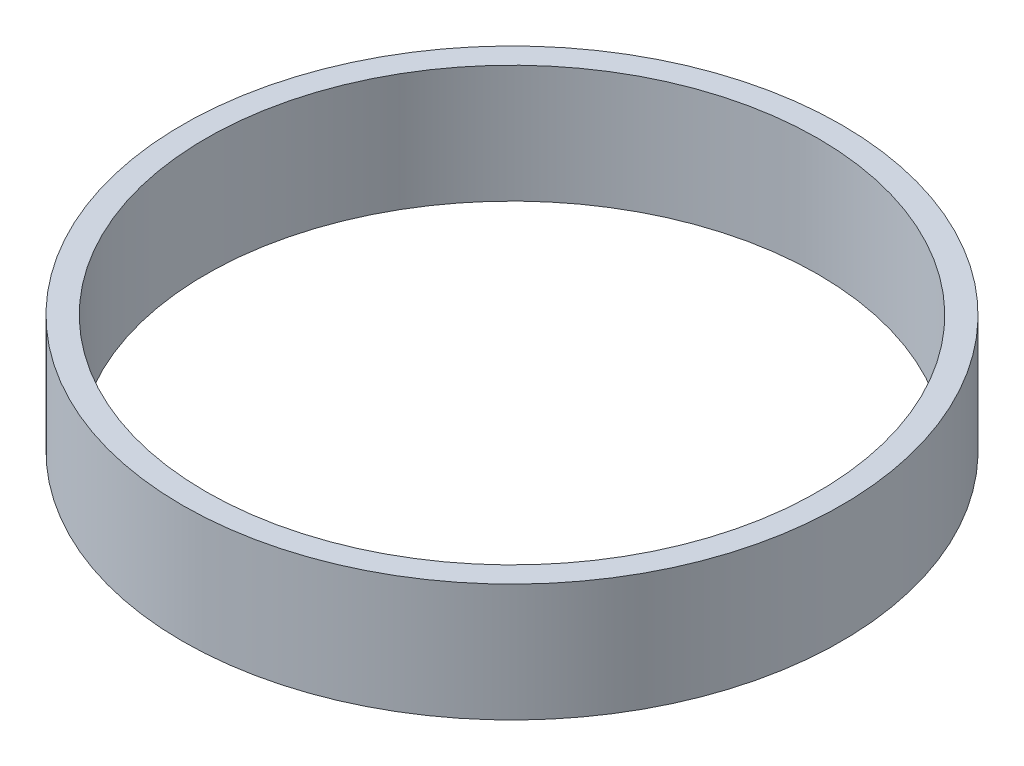
from build123d import *

# Parameters (mm, degrees)
SKETCH1_R           = 35
SKETCH1_R_2         = 32.5
BOSS_EXTRUDE1_DEPTH = 12.5


with BuildPart() as part:
    # Sketch1 → Boss-Extrude1 (new body)
    with BuildSketch(Plane(origin=(0, 0, 0), x_dir=(1, 0, 0), z_dir=(0, 1, 0))):
        Circle(SKETCH1_R)
        Circle(SKETCH1_R_2, mode=Mode.SUBTRACT)
    extrude(amount=BOSS_EXTRUDE1_DEPTH)


solid = part.part
